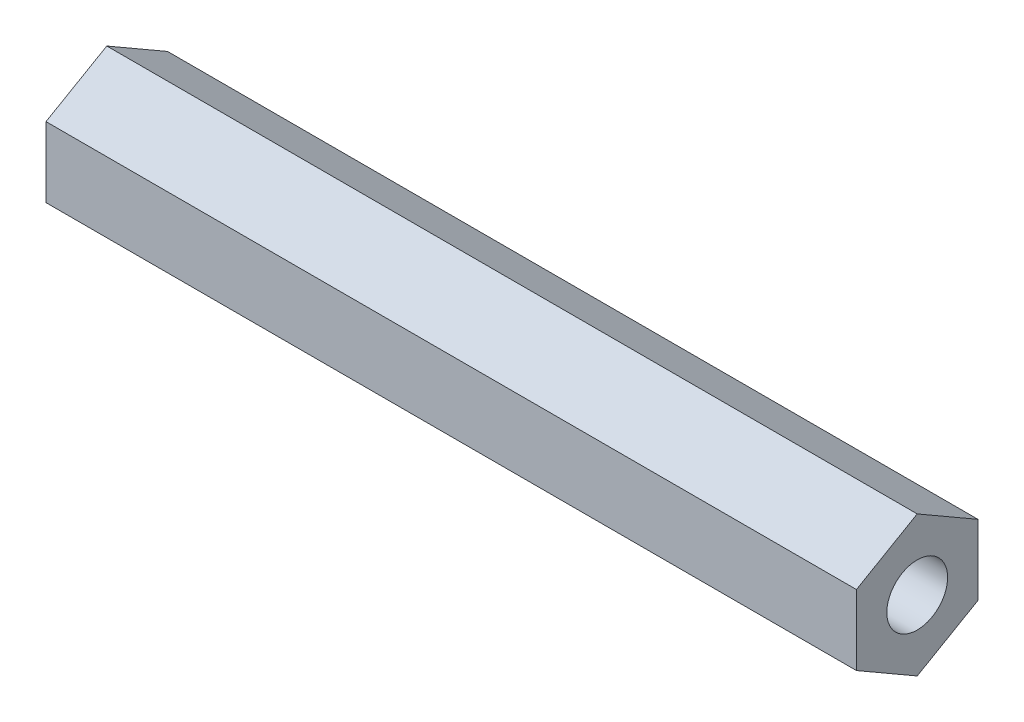
from build123d import *

# Parameters (mm, degrees)
SKETCH1_R           = 1.5
BOSS_EXTRUDE1_DEPTH = 40


with BuildPart() as part:
    # Sketch1 → Boss-Extrude1 (new body)
    with BuildSketch(Plane(origin=(0, 0, 0), x_dir=(0, 0, -1), z_dir=(1, 0, 0))):
        Polygon((-42.728336364, 8.277130653), (-45.728336364, 6.545079846), (-45.728336364, 3.08097823), (-42.728336364, 1.348927423), (-39.728336364, 3.08097823), (-39.728336364, 6.545079846), align=None)
        with Locations((-42.728336364, 4.813029038)):
            Circle(SKETCH1_R, mode=Mode.SUBTRACT)
    extrude(amount=BOSS_EXTRUDE1_DEPTH)


solid = part.part
